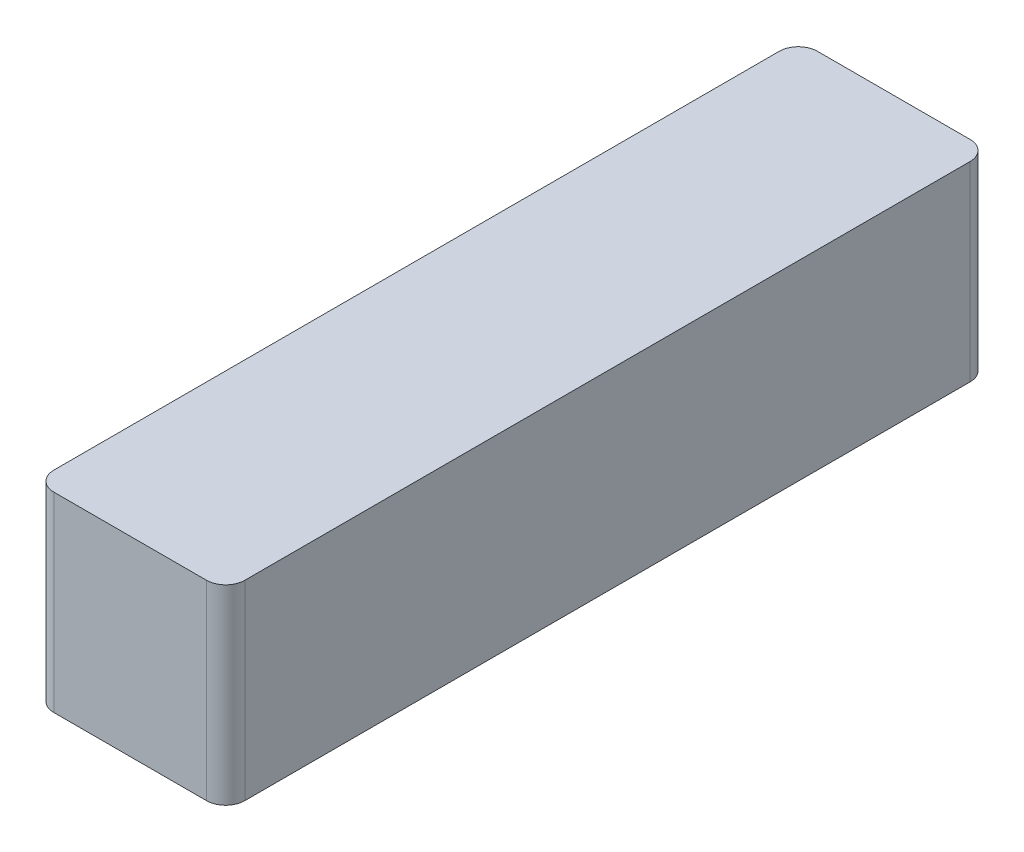
from build123d import *

# Parameters (mm, degrees)
SKETCH1_W           = 10
SKETCH1_H           = 40
BOSS_EXTRUDE1_DEPTH = 10
FILLET1_R           = 1


with BuildPart() as part:
    # Sketch1 → Boss-Extrude1 (new body)
    with BuildSketch(Plane(origin=(0, 0, 0), x_dir=(1, 0, 0), z_dir=(0, 1, 0))):
        with Locations((5, 20)):
            Rectangle(SKETCH1_W, SKETCH1_H)
    extrude(amount=BOSS_EXTRUDE1_DEPTH)

    # Fillet1
    fillet1_edges = [part.edges().sort_by_distance(p)[0] for p in [
        (0, 5, -40),
        (10, 5, -40),
        (10, 5, 0),
        (0, 5, 0),
    ]]
    fillet(fillet1_edges, radius=FILLET1_R)


solid = part.part
